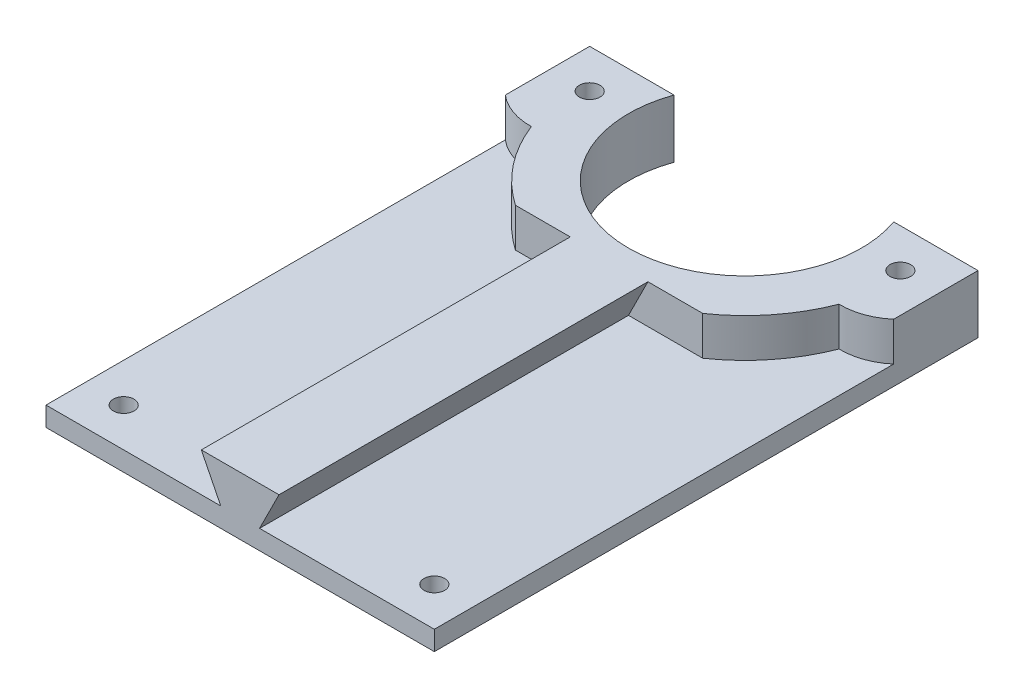
from build123d import *

# Parameters (mm, degrees)
SKETCH1_W                    = 127
SKETCH1_H                    = 177.8
BOSS_EXTRUDE1_DEPTH          = 6.35
H_0_266_DIAMETER_HOLE1_D     = 6.7564
H_0_266_DIAMETER_HOLE1_DEPTH = 16.51
H_0_266_DIAMETER_HOLE1_TIP   = 2.029827343
SKETCH4_R                    = 38.1
CUT_EXTRUDE1_DEPTH           = 6.35
SKETCH5_R                    = 3.3782
BOSS_EXTRUDE2_DEPTH          = 12.7
BOSS_EXTRUDE3_DEPTH          = 121.666
SKETCH7_W                    = 27.292671225
SKETCH7_H                    = 12.7
CUT_EXTRUDE2_DEPTH           = 120.65


with BuildPart() as part:
    # Sketch1 → Boss-Extrude1 (new body)
    with BuildSketch(Plane(origin=(0, 0, 0), x_dir=(1, 0, 0), z_dir=(0, 1, 0))):
        Rectangle(SKETCH1_W, SKETCH1_H)
    extrude(amount=BOSS_EXTRUDE1_DEPTH)

    # H (0.266) Diameter Hole1
    with Locations(Plane(origin=(0, 6.35, 0), x_dir=(1, 0, 0), z_dir=(0, 1, 0))):
        with Locations((-50.8, 76.2), (50.8, -76.2), (50.8, 76.2), (-50.8, -76.2)):
            Hole(H_0_266_DIAMETER_HOLE1_D / 2, depth=H_0_266_DIAMETER_HOLE1_DEPTH)
            with Locations((0, 0, -(H_0_266_DIAMETER_HOLE1_DEPTH + H_0_266_DIAMETER_HOLE1_TIP / 2))):  # 118° drill point
                Cone(0, H_0_266_DIAMETER_HOLE1_D / 2, H_0_266_DIAMETER_HOLE1_TIP, mode=Mode.SUBTRACT)

    # Sketch4 → Cut-Extrude1 (cut)
    with BuildSketch(Plane(origin=(0, 6.35, 0), x_dir=(1, 0, 0), z_dir=(0, 1, 0))):
        with Locations((0, 76.2)):
            Circle(SKETCH4_R)
    extrude(amount=-CUT_EXTRUDE1_DEPTH, mode=Mode.SUBTRACT)

    # Sketch5 → Boss-Extrude2 (add)
    with BuildSketch(Plane(origin=(0, 6.35, 0), x_dir=(1, 0, 0), z_dir=(0, 1, 0))):
        with BuildLine():
            Line((-35.921024484, 88.9), (-63.5, 88.9))
            Line((-63.5, 88.9), (-63.5, 61.321024484))
            ThreePointArc((-63.5, 61.321024484), (-57.336478943, 57.762311549), (-50.307743234, 56.644141653))
            ThreePointArc((-50.307743234, 56.644141653), (0, 22.225), (50.307743234, 56.644141653))
            ThreePointArc((50.307743234, 56.644141653), (57.336478943, 57.762311549), (63.5, 61.321024484))
            Line((63.5, 61.321024484), (63.5, 88.9))
            Line((63.5, 88.9), (35.921024484, 88.9))
            ThreePointArc((35.921024484, 88.9), (0, 38.1), (-35.921024484, 88.9))
        make_face()
        with Locations(Location((50.8, 76.2, 0), (0, 0, 270))):
            Circle(SKETCH5_R, mode=Mode.SUBTRACT)
        with Locations(Location((-50.8, 76.2, 0), (0, 0, 270))):
            Circle(SKETCH5_R, mode=Mode.SUBTRACT)
    extrude(amount=BOSS_EXTRUDE2_DEPTH)

    # Sketch6 → Boss-Extrude3 (add)
    with BuildSketch(Plane.XY.offset(88.9)):
        Polygon((-12.7, 19.05), (-6.35, 6.35), (6.35, 6.35), (12.7, 19.05), align=None)
    extrude(amount=-BOSS_EXTRUDE3_DEPTH)

    # Sketch7 → Cut-Extrude2 (cut)
    with BuildSketch(Plane.XY.offset(88.9)):
        with Locations((-36.661407622, 12.7)):
            Rectangle(SKETCH7_W, SKETCH7_H)
        Polygon((-23.015072009, 19.05), (-23.015072009, 6.35), (-6.35, 6.35), (-12.7, 19.05), align=None)
        Polygon((6.35, 6.35), (23.015072009, 6.35), (23.015072009, 19.05), (12.7, 19.05), align=None)
        with Locations((36.661407622, 12.7)):
            Rectangle(SKETCH7_W, SKETCH7_H)
    extrude(amount=-CUT_EXTRUDE2_DEPTH, mode=Mode.SUBTRACT)


solid = part.part
